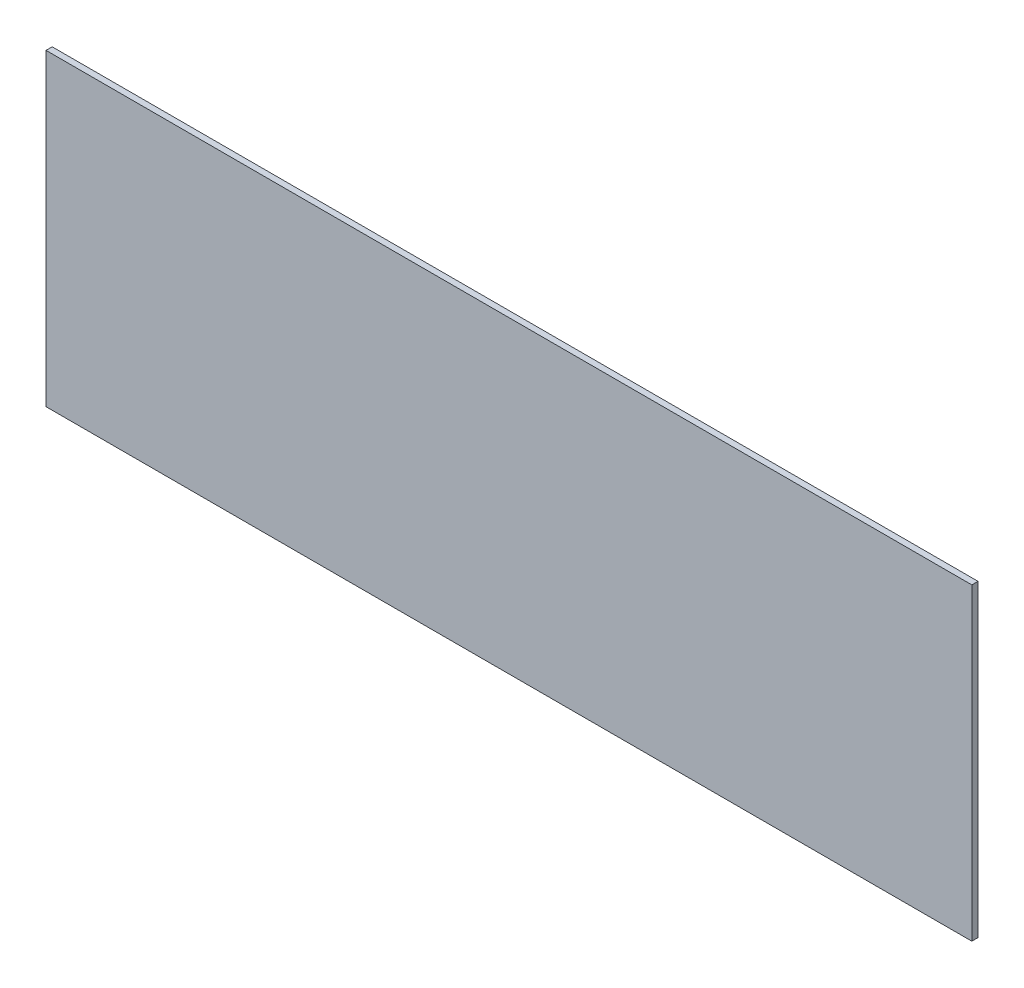
from build123d import *

# Parameters (mm, degrees)
SKETCH1_W           = 600
SKETCH1_H           = 200
BOSS_EXTRUDE1_DEPTH = 4


with BuildPart() as part:
    # Sketch1 → Boss-Extrude1 (new body)
    with BuildSketch(Plane.XY):
        with Locations((300, 100)):
            Rectangle(SKETCH1_W, SKETCH1_H)
    extrude(amount=BOSS_EXTRUDE1_DEPTH)


solid = part.part
